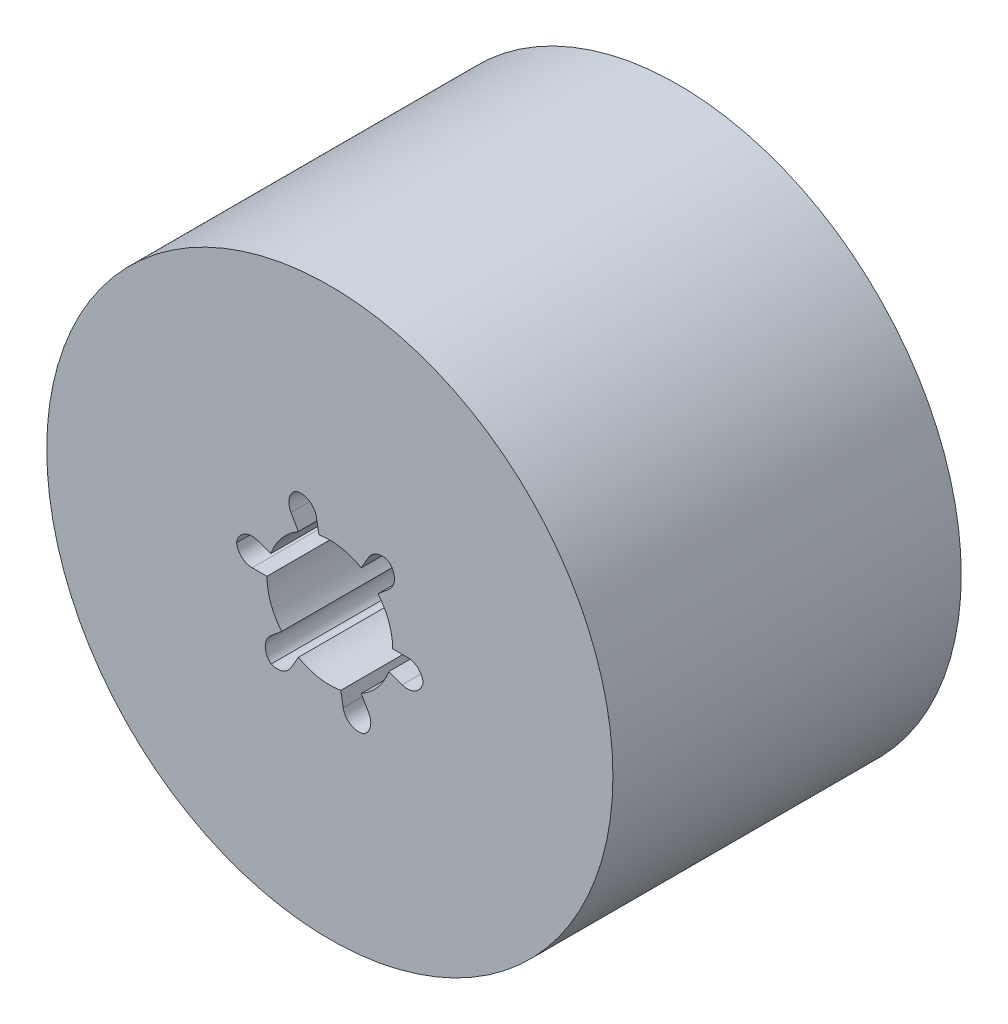
from build123d import *

# Parameters (mm, degrees)
SKETCH1_W                      = 22.51077
SKETCH1_H                      = 27.7
CUT_EXTRUDE1_DEPTH             = 18.95
F_7_5_7_5_DIAMETER_HOLE1_D     = 7.5
F_7_5_7_5_DIAMETER_HOLE1_DEPTH = 3.75


with BuildPart() as part:
    # Sketch1 → Revolve1 (revolve)
    with BuildSketch(Plane(origin=(0, -43.060148556, 0), x_dir=(1, 0, 0), z_dir=(0, 1, 0))):
        with Locations((-73.512097724, -49.65)):
            Rectangle(SKETCH1_W, SKETCH1_H)
    revolve(axis=Axis((-84.767482724, -43.060148556, 35.8), (0, 0, 1)))

    # Sketch2 → Cut-Extrude1 (cut)
    with BuildSketch(Plane.XY.offset(63.5)):
        with BuildLine():
            Line((-85.635723612, -38.136109791), (-85.830856299, -37.029457332))
            ThreePointArc((-85.830856299, -37.029457332), (-86.451441226, -36.155700609), (-87.520742643, -36.083791354))
            ThreePointArc((-87.520742643, -36.083791354), (-87.997695155, -36.833554149), (-87.855939444, -37.7107846))
            Line((-87.855939444, -37.7107846), (-87.267482724, -38.730021537))
            ThreePointArc((-87.267482724, -38.730021537), (-88.597704939, -39.846210508), (-89.465945828, -41.350047839))
            Line((-89.465945828, -41.350047839), (-90.521901314, -40.965711474))
            ThreePointArc((-90.521901314, -40.965711474), (-91.588889296, -41.066275425), (-92.185815247, -41.956362989))
            ThreePointArc((-92.185815247, -41.956362989), (-91.774977875, -42.744297377), (-90.944396164, -43.060148556))
            Line((-90.944396164, -43.060148556), (-89.767482724, -43.060148556))
            ThreePointArc((-89.767482724, -43.060148556), (-89.465945828, -44.770249273), (-88.597704939, -46.274086605))
            Line((-88.597704939, -46.274086605), (-89.458527739, -46.996402698))
            ThreePointArc((-89.458527739, -46.996402698), (-89.904930794, -47.970723371), (-89.432555327, -48.932720191))
            ThreePointArc((-89.432555327, -48.932720191), (-88.544765444, -48.970891785), (-87.855939444, -48.409512512))
            Line((-87.855939444, -48.409512512), (-87.267482724, -47.390275575))
            ThreePointArc((-87.267482724, -47.390275575), (-85.635723612, -47.984187321), (-83.899241835, -47.984187321))
            Line((-83.899241835, -47.984187321), (-83.704109149, -49.09083978))
            ThreePointArc((-83.704109149, -49.09083978), (-83.083524222, -49.964596503), (-82.014222804, -50.036505758))
            ThreePointArc((-82.014222804, -50.036505758), (-81.537270293, -49.286742964), (-81.679026004, -48.409512512))
            Line((-81.679026004, -48.409512512), (-82.267482724, -47.390275575))
            ThreePointArc((-82.267482724, -47.390275575), (-80.937260508, -46.274086605), (-80.06901962, -44.770249273))
            Line((-80.06901962, -44.770249273), (-79.013064134, -45.154585638))
            ThreePointArc((-79.013064134, -45.154585638), (-77.946076152, -45.054021688), (-77.349150201, -44.163934124))
            ThreePointArc((-77.349150201, -44.163934124), (-77.759987572, -43.375999735), (-78.590569284, -43.060148556))
            Line((-78.590569284, -43.060148556), (-79.767482724, -43.060148556))
            ThreePointArc((-79.767482724, -43.060148556), (-80.06901962, -41.350047839), (-80.937260508, -39.846210508))
            Line((-80.937260508, -39.846210508), (-80.076437709, -39.123894414))
            ThreePointArc((-80.076437709, -39.123894414), (-79.630034654, -38.149573741), (-80.10241012, -37.187576921))
            ThreePointArc((-80.10241012, -37.187576921), (-80.990200003, -37.149405327), (-81.679026004, -37.7107846))
            Line((-81.679026004, -37.7107846), (-82.267482724, -38.730021537))
            ThreePointArc((-82.267482724, -38.730021537), (-83.899241835, -38.136109791), (-85.635723612, -38.136109791))
        make_face()
    extrude(amount=-CUT_EXTRUDE1_DEPTH, mode=Mode.SUBTRACT)

    # Ø7.5 (7.5) Diameter Hole1
    with Locations(Plane.XY.offset(44.55)):
        with Locations((-84.767482724, -43.060148556)):
            Hole(F_7_5_7_5_DIAMETER_HOLE1_D / 2, depth=F_7_5_7_5_DIAMETER_HOLE1_DEPTH)


solid = part.part
